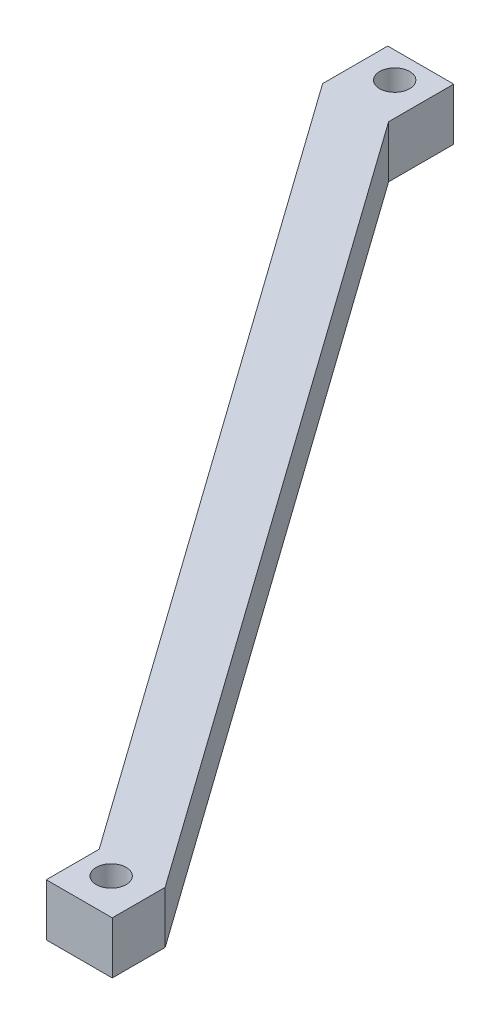
from build123d import *

# Parameters (mm, degrees)
BOSS_EXTRUDE2_DEPTH = 20
SKETCH3_R           = 5.75
CUT_EXTRUDE1_DEPTH  = 21


with BuildPart() as part:
    # Sketch2 → Boss-Extrude2 (new body)
    with BuildSketch(Plane(origin=(0, 0, 0), x_dir=(1, 0, 0), z_dir=(0, 1, 0))):
        Polygon((-12.666179626, 10), (-12.666179626, -15), (198.957090302, -312.389629316), (198.957090302, -332.698194406), (224.289449554, -332.698194406), (224.289449554, -312.389629316), (12.666179626, -15), (12.666179626, 10), align=None)
    extrude(amount=BOSS_EXTRUDE2_DEPTH)

    # Sketch3 → Cut-Extrude1 (cut, through all)
    with BuildSketch(Plane(origin=(0, 20, 0), x_dir=(1, 0, 0), z_dir=(0, 1, 0))):
        Circle(SKETCH3_R)
        with Locations((210.164682847, -318.99029152)):
            Circle(SKETCH3_R)
    extrude(amount=-CUT_EXTRUDE1_DEPTH, mode=Mode.SUBTRACT)


solid = part.part
